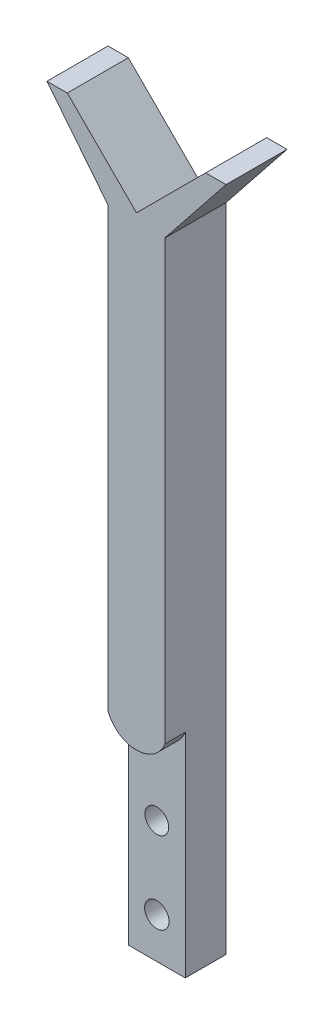
from build123d import *

# Parameters (mm, degrees)
BOSS_EXTRUDE1_DEPTH = 15
SKETCH2_R           = 2.925
SKETCH2_R_2         = 3
CUT_EXTRUDE1_DEPTH  = 16
CUT_EXTRUDE2_DEPTH  = 5


with BuildPart() as part:
    # Sketch1 → Boss-Extrude1 (new body)
    with BuildSketch(Plane.XY):
        Polygon((7, -2.83), (22, 16), (17, 16), (0, -1), (-17, 16), (-22, 16), (-7, -2.83), (-7, -162.83), (7, -162.83), align=None)
    extrude(amount=BOSS_EXTRUDE1_DEPTH)

    # Sketch2 → Cut-Extrude1 (cut, through all)
    with BuildSketch(Plane.XY.offset(15)):
        with Locations((0, -132.83)):
            Circle(SKETCH2_R)
        with Locations((0, -152.83)):
            Circle(SKETCH2_R_2)
    extrude(amount=-CUT_EXTRUDE1_DEPTH, mode=Mode.SUBTRACT)

    # Sketch3 → Cut-Extrude2 (cut)
    with BuildSketch(Plane.XY.offset(15)):
        with BuildLine():
            Line((-7, -110.522582404), (-7, -162.83))
            Line((-7, -162.83), (7, -162.83))
            Line((7, -162.83), (7, -110.522582404))
            ThreePointArc((7, -110.522582404), (0, -115.33), (-7, -110.522582404))
        make_face()
    extrude(amount=-CUT_EXTRUDE2_DEPTH, mode=Mode.SUBTRACT)


solid = part.part
